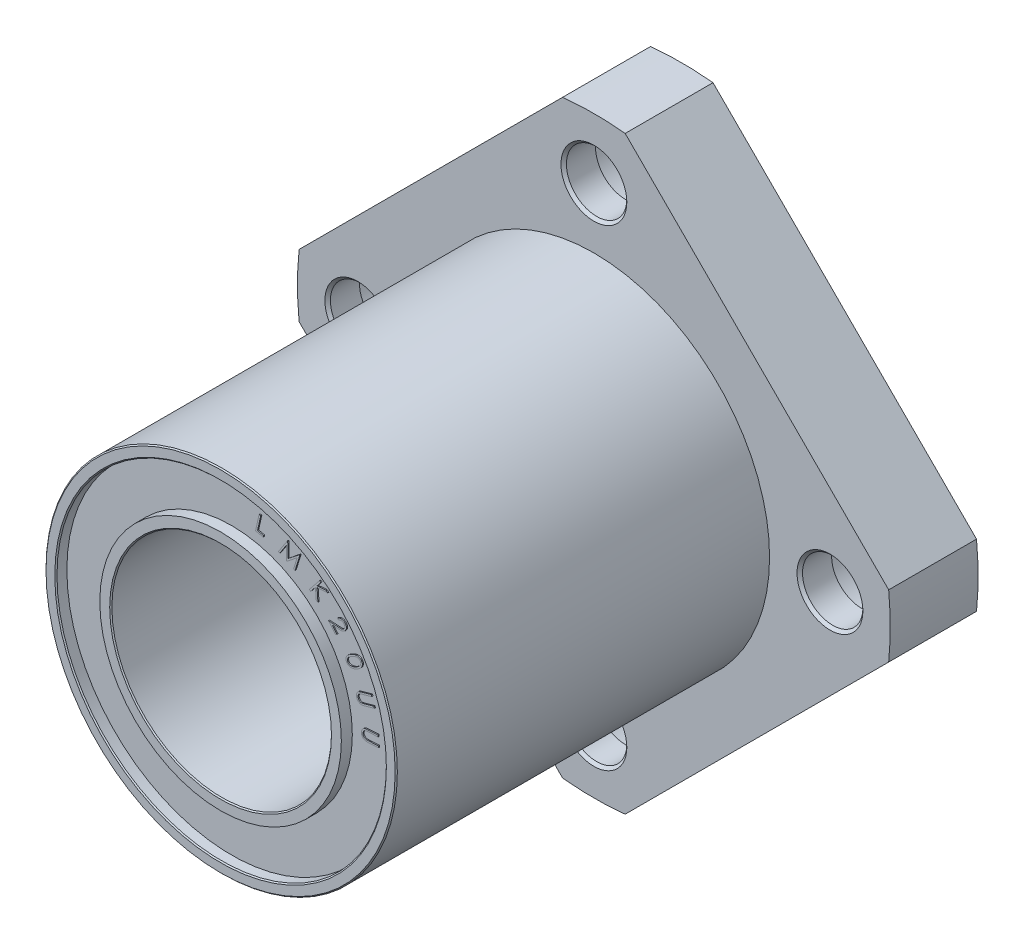
from build123d import *

# Parameters (mm, degrees)
BOSS_EXTRUDE1_DEPTH          = 8
SKETCH2_R                    = 16
BOSS_EXTRUDE2_DEPTH          = 34
SKETCH3_R                    = 4.5
CUT_EXTRUDE1_DEPTH           = 5.1
SKETCH4_R                    = 2.75
CUT_EXTRUDE2_DEPTH           = 2.9
CHAMFER1_SIZE                = 0.25
CIRPATTERN1_COUNT            = 4
CHAMFER1_OF_CIRPATTERN1_SIZE = 0.25
SKETCH5_R                    = 10
CUT_EXTRUDE3_DEPTH           = 43
SKETCH6_R                    = 15
SKETCH6_R_2                  = 11
CUT_EXTRUDE4_DEPTH           = 1
SKETCH7_R                    = 15
SKETCH7_R_2                  = 11
CUT_EXTRUDE5_DEPTH           = 1
BOSS_EXTRUDE3_DEPTH          = 0.1
CHAMFER2_SIZE                = 0.1
BOSS_EXTRUDE4_DEPTH          = 0.1


with BuildPart() as part:
    # Sketch1 → Boss-Extrude1 (new body)
    with BuildSketch(Plane.XY):
        with BuildLine():
            Line((-2.849242405, 26.849242405), (-26.849242405, 2.849242405))
            ThreePointArc((-26.849242405, 2.849242405), (-27, 0), (-26.849242405, -2.849242405))
            Line((-26.849242405, -2.849242405), (-2.849242405, -26.849242405))
            ThreePointArc((-2.849242405, -26.849242405), (0, -27), (2.849242405, -26.849242405))
            Line((2.849242405, -26.849242405), (26.849242405, -2.849242405))
            ThreePointArc((26.849242405, -2.849242405), (27, 0), (26.849242405, 2.849242405))
            Line((26.849242405, 2.849242405), (2.849242405, 26.849242405))
            ThreePointArc((2.849242405, 26.849242405), (0, 27), (-2.849242405, 26.849242405))
        make_face()
    extrude(amount=BOSS_EXTRUDE1_DEPTH)

    # Sketch2 → Boss-Extrude2 (add)
    with BuildSketch(Plane.XY.offset(8)):
        Circle(SKETCH2_R)
    extrude(amount=BOSS_EXTRUDE2_DEPTH)

    # Sketch3 → Cut-Extrude1 (cut)
    with BuildSketch(Plane(origin=(0, 0, 0), x_dir=(-1, 0, 0), z_dir=(0, 0, -1))):
        with Locations((0, 21.5)):
            Circle(SKETCH3_R)
    cut_extrude1 = extrude(amount=-CUT_EXTRUDE1_DEPTH, mode=Mode.SUBTRACT)

    # Sketch4 → Cut-Extrude2 (cut)
    with BuildSketch(Plane(origin=(0, 0, 5.1), x_dir=(-1, 0, 0), z_dir=(0, 0, -1))):
        with Locations((0, 21.5)):
            Circle(SKETCH4_R)
    cut_extrude2 = extrude(amount=-CUT_EXTRUDE2_DEPTH, mode=Mode.SUBTRACT)

    # Chamfer1
    chamfer1_edges = [part.edges().sort_by_distance(p)[0] for p in [
        (4.5, 21.5, 0),
        (2.75, 21.5, 8),
    ]]
    chamfer(chamfer1_edges, length=CHAMFER1_SIZE)

    # CirPattern1: Cut-Extrude1, Cut-Extrude2 ×4 about axis
    cirpattern1_axis = Axis((0, 0, 0), (0, 0, 1))
    for i in range(1, CIRPATTERN1_COUNT):
        add(cut_extrude1.rotate(cirpattern1_axis, i * 360 / CIRPATTERN1_COUNT), mode=Mode.SUBTRACT)
        add(cut_extrude2.rotate(cirpattern1_axis, i * 360 / CIRPATTERN1_COUNT), mode=Mode.SUBTRACT)

    # Chamfer1 of CirPattern1
    chamfer1_of_cirpattern1_edges = [part.edges().sort_by_distance(p)[0] for p in [
        (-21.5, 4.5, 0),
        (-21.5, 2.75, 8),
        (-4.5, -21.5, 0),
        (-2.75, -21.5, 8),
        (21.5, -4.5, 0),
        (21.5, -2.75, 8),
    ]]
    chamfer(chamfer1_of_cirpattern1_edges, length=CHAMFER1_OF_CIRPATTERN1_SIZE)

    # Sketch5 → Cut-Extrude3 (cut, through all)
    with BuildSketch(Plane.XY.offset(42)):
        Circle(SKETCH5_R)
    extrude(amount=-CUT_EXTRUDE3_DEPTH, mode=Mode.SUBTRACT)

    # Sketch6 → Cut-Extrude4 (cut)
    with BuildSketch(Plane.XY.offset(42)):
        Circle(SKETCH6_R)
        Circle(SKETCH6_R_2, mode=Mode.SUBTRACT)
    extrude(amount=-CUT_EXTRUDE4_DEPTH, mode=Mode.SUBTRACT)

    # Sketch7 → Cut-Extrude5 (cut)
    with BuildSketch(Plane(origin=(0, 0, 0), x_dir=(-1, 0, 0), z_dir=(0, 0, -1))):
        Circle(SKETCH7_R)
        Circle(SKETCH7_R_2, mode=Mode.SUBTRACT)
    extrude(amount=-CUT_EXTRUDE5_DEPTH, mode=Mode.SUBTRACT)

    # Sketch8 → Boss-Extrude3 (add)
    with BuildSketch(Plane.XY.offset(41)):
        with BuildLine():
            Line((13.427089752, 1.23927114), (13.435202732, 1.090232679))
            Line((13.435202732, 1.090232679), (12.534661867, 1.039751909))
            add(Edge.make_bspline(
                [(12.534661867, 1.039751909), (12.521938092, 1.039105283), (12.497682448, 1.037872603), (12.463252241, 1.035275518), (12.432586914, 1.033302619), (12.405842357, 1.031197911), (12.38290086, 1.029112812), (12.363764001, 1.02704565), (12.348313102, 1.025044585), (12.339344068, 1.023358043), (12.335443117, 1.022624506)],
                knots=[0, 0, 0, 0, 3.8219e-05, 7.2858e-05, 0.000103579, 0.000130404, 0.000153337, 0.000172683, 0.000188151, 0.000200057, 0.000200057, 0.000200057, 0.000200057], degree=3))
            add(Edge.make_bspline(
                [(12.335443117, 1.022624506), (12.321327399, 1.019661816), (12.294081466, 1.013943279), (12.255805741, 0.999996763), (12.221149074, 0.983428508), (12.189942518, 0.962987015), (12.162506723, 0.937659089), (12.137484031, 0.90766722), (12.116197683, 0.871686149), (12.097208807, 0.831951848), (12.082455491, 0.789484408), (12.072116386, 0.746434196), (12.066635935, 0.703351793), (12.067356, 0.674780167), (12.067714752, 0.660545179)],
                knots=[0, 0, 0, 0, 4.322e-05, 8.3423e-05, 0.000121857, 0.000158276, 0.000194861, 0.000233488, 0.000275024, 0.000319916, 0.000365436, 0.000409602, 0.000452575, 0.000495244, 0.000495244, 0.000495244, 0.000495244], degree=3))
            add(Edge.make_bspline(
                [(12.067714752, 0.660545179), (12.068696913, 0.648278297), (12.070648098, 0.623908614), (12.079246417, 0.588237365), (12.090870833, 0.553427222), (12.106487478, 0.520023427), (12.125257958, 0.488484833), (12.147416847, 0.459702961), (12.172426236, 0.4338272), (12.200184275, 0.410693877), (12.231077449, 0.391313874), (12.26437645, 0.374537533), (12.300584605, 0.361243554), (12.326053685, 0.355289747), (12.339048886, 0.352251909)],
                knots=[0, 0, 0, 0, 3.6866e-05, 7.3239e-05, 0.000109728, 0.000146832, 0.000183626, 0.000219626, 0.000255539, 0.000291396, 0.000327739, 0.000364693, 0.000403099, 0.000443109, 0.000443109, 0.000443109, 0.000443109], degree=3))
            add(Edge.make_bspline(
                [(12.339048886, 0.352251909), (12.344445352, 0.35125697), (12.356472762, 0.349039491), (12.376602623, 0.347680621), (12.400317816, 0.345951944), (12.427792454, 0.34547477), (12.458940627, 0.345987565), (12.493809349, 0.34637775), (12.532367597, 0.348057356), (12.559302463, 0.349429274), (12.573423886, 0.350148544)],
                knots=[0, 0, 0, 0, 1.645e-05, 3.6663e-05, 6.0448e-05, 8.7798e-05, 0.00011905, 0.000153911, 0.000192402, 0.000234822, 0.000234822, 0.000234822, 0.000234822], degree=3))
            Line((12.573423886, 0.350148544), (13.473964752, 0.400629313))
            Line((13.473964752, 0.400629313), (13.482378213, 0.251590852))
            Line((13.482378213, 0.251590852), (12.581837348, 0.201110082))
            add(Edge.make_bspline(
                [(12.581837348, 0.201110082), (12.56561504, 0.200299528), (12.533884566, 0.198714101), (12.487384842, 0.198232005), (12.443199362, 0.198783334), (12.401298345, 0.200489862), (12.361692312, 0.203734651), (12.324410009, 0.208563237), (12.289523247, 0.214566137), (12.256604326, 0.221633293), (12.225359503, 0.231069465), (12.195123236, 0.242731892), (12.166051243, 0.257342613), (12.137532203, 0.273927513), (12.10986458, 0.293061464), (12.083546361, 0.31532073), (12.057466873, 0.339293333), (12.032750759, 0.365901306), (12.009598728, 0.394545285), (11.989149564, 0.425202797), (11.971616871, 0.457618882), (11.956854527, 0.491706309), (11.944867901, 0.527512315), (11.935569746, 0.564986558), (11.928758933, 0.604143572), (11.926855925, 0.630971712), (11.925887829, 0.644619698)],
                knots=[0, 0, 0, 0, 4.8723e-05, 9.5302e-05, 0.000139476, 0.000181282, 0.000221083, 0.000258652, 0.000294022, 0.000327265, 0.000359586, 0.000391839, 0.000424359, 0.000457083, 0.000490759, 0.000525115, 0.000560408, 0.000596976, 0.000633954, 0.00067079, 0.000707361, 0.00074437, 0.000782093, 0.0008205, 0.000860118, 0.000901142, 0.000901142, 0.000901142, 0.000901142], degree=3))
            add(Edge.make_bspline(
                [(11.925887829, 0.644619698), (11.92526274, 0.659442192), (11.924037588, 0.688493761), (11.92605034, 0.731463494), (11.930449834, 0.772930422), (11.937674288, 0.813001355), (11.947567537, 0.851717442), (11.960457025, 0.888897117), (11.976261989, 0.924602831), (11.99442907, 0.958727457), (12.015113065, 0.990726777), (12.037723114, 1.02046248), (12.062470061, 1.047384184), (12.088606594, 1.072323824), (12.116996039, 1.094376799), (12.147475956, 1.113405297), (12.179413753, 1.1306766), (12.202025381, 1.13954085), (12.213447925, 1.144018736)],
                knots=[0, 0, 0, 0, 4.4487e-05, 8.7194e-05, 0.000128904, 0.000169514, 0.000209233, 0.000248669, 0.000287416, 0.000326267, 0.000364523, 0.000401604, 0.000438189, 0.000474113, 0.000509875, 0.000545803, 0.000581826, 0.0006186, 0.0006186, 0.0006186, 0.0006186], degree=3))
            add(Edge.make_bspline(
                [(12.213447925, 1.144018736), (12.221321464, 1.146755288), (12.238264541, 1.152644078), (12.266615842, 1.159209917), (12.299159447, 1.16582175), (12.336136628, 1.171840261), (12.377473834, 1.176691337), (12.423116468, 1.181707219), (12.473345979, 1.185357946), (12.508318501, 1.187614224), (12.526548886, 1.188790371)],
                knots=[0, 0, 0, 0, 2.4991e-05, 5.3777e-05, 8.719e-05, 0.000124635, 0.000166116, 0.000212042, 0.000262374, 0.00031718, 0.00031718, 0.00031718, 0.00031718], degree=3))
            Line((12.526548886, 1.188790371), (13.427089752, 1.23927114))
        make_face()
        with BuildLine():
            Line((12.834294046, 4.128094889), (12.874558469, 3.984465081))
            Line((12.874558469, 3.984465081), (12.007370969, 3.740775178))
            add(Edge.make_bspline(
                [(12.007370969, 3.740775178), (11.995148675, 3.737279133), (11.971894452, 3.730627534), (11.93884085, 3.721012984), (11.909481631, 3.712339927), (11.883700624, 3.704547159), (11.861821774, 3.697354), (11.843427123, 3.691336213), (11.828864323, 3.686094514), (11.820460038, 3.682511632), (11.816866161, 3.680979504)],
                knots=[0, 0, 0, 0, 3.8137e-05, 7.256e-05, 0.00010327, 0.000129979, 0.000153355, 0.000172359, 0.000188044, 0.000199763, 0.000199763, 0.000199763, 0.000199763], degree=3))
            add(Edge.make_bspline(
                [(11.816866161, 3.680979504), (11.803786347, 3.675073174), (11.77843311, 3.663624646), (11.744051277, 3.641922979), (11.713611167, 3.618369949), (11.687896111, 3.591432709), (11.66631477, 3.560932882), (11.648912716, 3.526063187), (11.635562273, 3.486592235), (11.625820652, 3.443703883), (11.620537366, 3.3990839), (11.619755566, 3.354753166), (11.624228503, 3.311571603), (11.630863311, 3.283785918), (11.634173853, 3.269921812)],
                knots=[0, 0, 0, 0, 4.3007e-05, 8.3362e-05, 0.000121655, 0.00015821, 0.000194643, 0.000233344, 0.000274681, 0.000319364, 0.000365058, 0.000409233, 0.000452139, 0.000494867, 0.000494867, 0.000494867, 0.000494867], degree=3))
            add(Edge.make_bspline(
                [(11.634173853, 3.269921812), (11.637821783, 3.258306654), (11.645112071, 3.235094073), (11.660642257, 3.202115426), (11.679438717, 3.170704792), (11.701866493, 3.141517895), (11.72722005, 3.114876869), (11.755110877, 3.091593222), (11.784949964, 3.071589328), (11.817114568, 3.055229831), (11.851400312, 3.042590517), (11.887729631, 3.033993162), (11.925882763, 3.028704828), (11.951964508, 3.028261518), (11.965303661, 3.028034793)],
                knots=[0, 0, 0, 0, 3.6488e-05, 7.2921e-05, 0.000109045, 0.000146126, 0.000183106, 0.000219155, 0.000254907, 0.000290653, 0.000327158, 0.000364254, 0.000402458, 0.00044245, 0.00044245, 0.00044245, 0.00044245], degree=3))
            add(Edge.make_bspline(
                [(11.965303661, 3.028034793), (11.970818508, 3.028259408), (11.982989716, 3.028755131), (12.002932587, 3.031403005), (12.026374242, 3.035342348), (12.053331039, 3.040759008), (12.083627511, 3.047817533), (12.117469716, 3.055795994), (12.154624282, 3.065933256), (12.180647962, 3.07300893), (12.194270007, 3.076712678)],
                knots=[0, 0, 0, 0, 1.6551e-05, 3.6528e-05, 6.0289e-05, 8.7868e-05, 0.000118993, 0.000153611, 0.000192167, 0.000234518, 0.000234518, 0.000234518, 0.000234518], degree=3))
            Line((12.194270007, 3.076712678), (13.061457507, 3.320402581))
            Line((13.061457507, 3.320402581), (13.10172193, 3.176772774))
            Line((13.10172193, 3.176772774), (12.23453443, 2.93308287))
            add(Edge.make_bspline(
                [(12.23453443, 2.93308287), (12.218832169, 2.928787142), (12.188225823, 2.920414047), (12.143121106, 2.90966115), (12.100091957, 2.900418417), (12.058835945, 2.893666564), (12.019583265, 2.888161238), (11.982301451, 2.884367706), (11.946989434, 2.883060996), (11.913381772, 2.882737102), (11.880803855, 2.885131743), (11.848888101, 2.890364189), (11.81719988, 2.897816481), (11.785848698, 2.908095411), (11.754898615, 2.921143119), (11.724105665, 2.936464974), (11.693710364, 2.954598379), (11.66387792, 2.975235683), (11.63500541, 2.997957007), (11.608916481, 3.023959675), (11.584388485, 3.051343459), (11.56274529, 3.081511297), (11.54297699, 3.11357717), (11.526499372, 3.148477821), (11.511056366, 3.18496689), (11.503424522, 3.210641713), (11.499558469, 3.223647774)],
                knots=[0, 0, 0, 0, 4.8834e-05, 9.5186e-05, 0.000139091, 0.000180832, 0.000220565, 0.000257999, 0.000293187, 0.000326541, 0.000358782, 0.00039104, 0.000423472, 0.00045635, 0.000489888, 0.000524155, 0.000559455, 0.000595961, 0.00063294, 0.000669488, 0.00070632, 0.000743103, 0.000780721, 0.000819156, 0.000858774, 0.000899447, 0.000899447, 0.000899447, 0.000899447], degree=3))
            add(Edge.make_bspline(
                [(11.499558469, 3.223647774), (11.49571903, 3.237918695), (11.488151139, 3.266048005), (11.480991418, 3.308517717), (11.475811364, 3.350017065), (11.474561282, 3.390710867), (11.475472581, 3.430502197), (11.480152495, 3.469475107), (11.487601849, 3.507667833), (11.498122735, 3.544829455), (11.511287374, 3.580494236), (11.526909233, 3.61429321), (11.545090085, 3.646000735), (11.56539948, 3.675800628), (11.58841597, 3.703308504), (11.613884387, 3.728582558), (11.641360965, 3.752270419), (11.66156936, 3.765813917), (11.671733949, 3.772626139)],
                knots=[0, 0, 0, 0, 4.4309e-05, 8.7338e-05, 0.000129082, 0.000169675, 0.000209357, 0.00024838, 0.000287273, 0.000325989, 0.000364112, 0.000401216, 0.000437554, 0.000473643, 0.000509269, 0.000544964, 0.000581207, 0.000617885, 0.000617885, 0.000617885, 0.000617885], degree=3))
            add(Edge.make_bspline(
                [(11.671733949, 3.772626139), (11.678795257, 3.776921276), (11.694125667, 3.786246207), (11.72006606, 3.799306383), (11.75040416, 3.812695119), (11.785156887, 3.826598108), (11.824410878, 3.840524247), (11.867995711, 3.854934195), (11.916005786, 3.869681719), (11.949562826, 3.879350249), (11.967106546, 3.884404985)],
                knots=[0, 0, 0, 0, 2.4787e-05, 5.3815e-05, 8.7039e-05, 0.000124256, 0.000166076, 0.000211971, 0.000261965, 0.000316736, 0.000316736, 0.000316736, 0.000316736], degree=3))
            Line((11.967106546, 3.884404985), (12.834294046, 4.128094889))
        make_face()
        with BuildLine():
            add(Edge.make_bspline(
                [(11.027657403, 6.390487463), (11.049019815, 6.401549045), (11.090436991, 6.422995102), (11.151920651, 6.451854378), (11.210515223, 6.477182902), (11.266282658, 6.498919018), (11.319335723, 6.516749785), (11.369562348, 6.53094796), (11.417063796, 6.541735716), (11.462200682, 6.548275744), (11.505148692, 6.551941832), (11.546405499, 6.552938244), (11.586239167, 6.551029405), (11.624638332, 6.547056318), (11.66163435, 6.539899668), (11.69729367, 6.53084512), (11.731536462, 6.518660489), (11.764123922, 6.503956686), (11.795185285, 6.487119279), (11.824425036, 6.468133844), (11.851762437, 6.447137086), (11.87708028, 6.424129641), (11.900790599, 6.399393497), (11.922274965, 6.372358807), (11.941958033, 6.343415315), (11.953386918, 6.322969107), (11.959147788, 6.312662944)],
                knots=[0, 0, 0, 0, 7.2164e-05, 0.00013991, 0.000203709, 0.000263639, 0.000319416, 0.000371546, 0.000420173, 0.00046543, 0.00050825, 0.000549426, 0.000589131, 0.000627821, 0.000665126, 0.000702076, 0.000738095, 0.000774005, 0.000809233, 0.000843988, 0.000878485, 0.000912523, 0.00094653, 0.000981162, 0.001015998, 0.001051405, 0.001051405, 0.001051405, 0.001051405], degree=3))
            add(Edge.make_bspline(
                [(11.959147788, 6.312662944), (11.964533418, 6.301926237), (11.975225571, 6.280610535), (11.988014556, 6.247478369), (11.99831124, 6.214053185), (12.005929292, 6.180102602), (12.010642853, 6.145629609), (12.012907379, 6.110663629), (12.01172646, 6.075317316), (12.008658321, 6.039624069), (12.002215618, 6.003762363), (11.992952194, 5.967835613), (11.980217457, 5.932263981), (11.964757595, 5.896674226), (11.946124503, 5.861354836), (11.924328678, 5.826101113), (11.899679957, 5.79096312), (11.871945492, 5.755908443), (11.8404408, 5.721171085), (11.804946781, 5.686617732), (11.765179134, 5.652476416), (11.721368387, 5.618372418), (11.673322245, 5.584507299), (11.620986888, 5.551007924), (11.564684275, 5.517409172), (11.525144866, 5.496293328), (11.504820865, 5.485439386)],
                knots=[0, 0, 0, 0, 3.6018e-05, 7.1506e-05, 0.000106389, 0.000140871, 0.000175759, 0.000210678, 0.000245846, 0.000281756, 0.000318066, 0.000355016, 0.000392935, 0.000431286, 0.000471339, 0.000512619, 0.00055555, 0.000600037, 0.000646627, 0.000696137, 0.000748545, 0.000803783, 0.000862641, 0.00092482, 0.000990163, 0.001059276, 0.001059276, 0.001059276, 0.001059276], degree=3))
            add(Edge.make_bspline(
                [(11.504820865, 5.485439386), (11.484478447, 5.474838825), (11.444857732, 5.454192222), (11.385504049, 5.427100269), (11.328740793, 5.402750414), (11.273927596, 5.382409128), (11.221437047, 5.36495116), (11.170873271, 5.351906365), (11.122693688, 5.341675525), (11.076478269, 5.335428525), (11.032224478, 5.332092146), (10.989572937, 5.331431929), (10.948410941, 5.333484597), (10.908758531, 5.338284444), (10.870640261, 5.345605065), (10.833911081, 5.354910419), (10.798920147, 5.367890943), (10.765329849, 5.382643831), (10.733681183, 5.400244266), (10.70393797, 5.419837921), (10.675821615, 5.441098424), (10.650003525, 5.464640036), (10.626055045, 5.490030231), (10.604227939, 5.517475014), (10.58379061, 5.546589162), (10.572245025, 5.567457726), (10.566419422, 5.577987463)],
                knots=[0, 0, 0, 0, 6.8804e-05, 0.000134009, 0.000195678, 0.000254058, 0.000309361, 0.000361545, 0.000410633, 0.000457038, 0.000501332, 0.000543704, 0.000584924, 0.000624878, 0.000663419, 0.000701318, 0.000738388, 0.000775243, 0.000811287, 0.000846873, 0.000882031, 0.000916917, 0.000951567, 0.000986621, 0.001022045, 0.001058123, 0.001058123, 0.001058123, 0.001058123], degree=3))
            add(Edge.make_bspline(
                [(10.566419422, 5.577987463), (10.56116293, 5.58853573), (10.55071185, 5.609508036), (10.537787073, 5.641904601), (10.52779283, 5.674893699), (10.520725253, 5.708290711), (10.51564689, 5.741995516), (10.514118563, 5.77618613), (10.514475397, 5.810751986), (10.518296319, 5.845694899), (10.524457647, 5.880801885), (10.53386549, 5.915767193), (10.546236042, 5.950425969), (10.56169767, 5.984838901), (10.580100217, 6.018990799), (10.601108339, 6.05319948), (10.625655929, 6.086661596), (10.652800871, 6.120455298), (10.684060155, 6.153950756), (10.719558242, 6.187590022), (10.759769055, 6.221299094), (10.804497672, 6.255039673), (10.853620067, 6.289176226), (10.907561867, 6.322907296), (10.965761227, 6.357293448), (11.006641226, 6.379216795), (11.027657403, 6.390487463)],
                knots=[0, 0, 0, 0, 3.5346e-05, 7.0275e-05, 0.000104496, 0.00013862, 0.000172615, 0.000206618, 0.000241178, 0.00027622, 0.000311938, 0.000348017, 0.000384703, 0.000422229, 0.000461079, 0.000501021, 0.000542554, 0.000585493, 0.000630994, 0.000679879, 0.000732125, 0.000788316, 0.000847913, 0.00091152, 0.000979133, 0.001050668, 0.001050668, 0.001050668, 0.001050668], degree=3))
        make_face()
        with BuildLine():
            add(Edge.make_bspline(
                [(11.091058845, 6.263684578), (11.072989793, 6.253942202), (11.0380584, 6.235108077), (10.987950638, 6.206543255), (10.942041243, 6.178397805), (10.90019934, 6.150670143), (10.862169481, 6.123821687), (10.828637678, 6.097041277), (10.798828088, 6.07120313), (10.773154279, 6.045481762), (10.750624084, 6.01994828), (10.730671648, 5.994245707), (10.712951286, 5.968338619), (10.697882581, 5.941920133), (10.684828286, 5.915506021), (10.674283193, 5.888669625), (10.666091707, 5.861539716), (10.658716433, 5.82562749), (10.654309202, 5.78158653), (10.657283474, 5.730286624), (10.668069744, 5.68149279), (10.681854809, 5.651705607), (10.688715095, 5.636881694)],
                knots=[0, 0, 0, 0, 6.1583e-05, 0.000119054, 0.000173011, 0.000223097, 0.000269624, 0.00031261, 0.000351788, 0.000387908, 0.000421546, 0.000453882, 0.000485468, 0.00051562, 0.00054505, 0.000573786, 0.00060202, 0.000629954, 0.000683683, 0.000734253, 0.000783599, 0.000832485, 0.000832485, 0.000832485, 0.000832485], degree=3))
            add(Edge.make_bspline(
                [(10.688715095, 5.636881694), (10.697048729, 5.622719797), (10.713708681, 5.594408433), (10.747602052, 5.557768223), (10.787757612, 5.526547665), (10.825964038, 5.505581106), (10.859009085, 5.491525996), (10.88568606, 5.483597508), (10.913357967, 5.477200983), (10.942293077, 5.472915079), (10.972545271, 5.471376209), (11.003963432, 5.471167509), (11.03656428, 5.473774612), (11.058519822, 5.476723102), (11.069724711, 5.478227848)],
                knots=[0, 0, 0, 0, 4.918e-05, 9.8316e-05, 0.000148626, 0.000201218, 0.000228562, 0.000256221, 0.000284576, 0.000313727, 0.000343829, 0.00037538, 0.000407921, 0.000441836, 0.000441836, 0.000441836, 0.000441836], degree=3))
            add(Edge.make_bspline(
                [(11.069724711, 5.478227848), (11.083872513, 5.480597407), (11.112712356, 5.485427677), (11.156177894, 5.495341564), (11.200516798, 5.50816731), (11.245904384, 5.523249127), (11.292430883, 5.540507799), (11.339677265, 5.560944065), (11.388059875, 5.583323344), (11.420243891, 5.599903728), (11.43661173, 5.608336021)],
                knots=[0, 0, 0, 0, 4.3029e-05, 8.7712e-05, 0.000133651, 0.000181446, 0.000231174, 0.000282466, 0.000335835, 0.000391065, 0.000391065, 0.000391065, 0.000391065], degree=3))
            add(Edge.make_bspline(
                [(11.43661173, 5.608336021), (11.452912329, 5.617017357), (11.484710566, 5.633952391), (11.530077276, 5.661000917), (11.572825996, 5.687448695), (11.612315862, 5.714680393), (11.648886514, 5.7419544), (11.68273332, 5.769133428), (11.713033865, 5.79702636), (11.740946337, 5.824492984), (11.765383964, 5.852666188), (11.787887144, 5.880106888), (11.807126067, 5.907919416), (11.823809862, 5.935569745), (11.837522298, 5.963302623), (11.849246441, 5.990642229), (11.857666357, 6.018170202), (11.865011387, 6.054107823), (11.869485775, 6.097949616), (11.866411677, 6.14881147), (11.856022914, 6.197275301), (11.842236834, 6.226732862), (11.835349711, 6.241449002)],
                knots=[0, 0, 0, 0, 5.5396e-05, 0.000108063, 0.00015842, 0.000206177, 0.000251911, 0.000295273, 0.000336324, 0.000375419, 0.000412675, 0.000448152, 0.000481828, 0.000514035, 0.000544942, 0.000574574, 0.000603183, 0.000631117, 0.000684546, 0.000734817, 0.000783509, 0.000832119, 0.000832119, 0.000832119, 0.000832119], degree=3))
            add(Edge.make_bspline(
                [(11.835349711, 6.241449002), (11.826892619, 6.255591228), (11.810013635, 6.283816818), (11.77614967, 6.320800088), (11.735249491, 6.351665946), (11.696792065, 6.373184609), (11.663126184, 6.386926129), (11.636488831, 6.395799653), (11.608558778, 6.401900819), (11.579592975, 6.406681258), (11.549321958, 6.408427317), (11.518006118, 6.40900799), (11.48562085, 6.406537206), (11.45175121, 6.402861831), (11.415920889, 6.396040145), (11.377647983, 6.386247579), (11.336556304, 6.373731424), (11.29288511, 6.357493413), (11.246297244, 6.338535839), (11.19686991, 6.316646604), (11.144657883, 6.291602504), (11.10933533, 6.273204181), (11.091058845, 6.263684578)],
                knots=[0, 0, 0, 0, 4.9342e-05, 9.8479e-05, 0.000149263, 0.000202527, 0.000230148, 0.000258275, 0.00028663, 0.000315826, 0.000346247, 0.000377499, 0.000409719, 0.000443599, 0.000479667, 0.00051902, 0.000562077, 0.000608466, 0.000658741, 0.000712956, 0.000770612, 0.00083243, 0.00083243, 0.00083243, 0.00083243], degree=3))
        make_face(mode=Mode.SUBTRACT)
        with BuildLine():
            Line((9.840154707, 8.509788227), (9.750010476, 8.619764188))
            add(Edge.make_bspline(
                [(9.750010476, 8.619764188), (9.764459331, 8.630437009), (9.792787316, 8.651361817), (9.837570375, 8.677887053), (9.883091207, 8.699700281), (9.929490469, 8.716619181), (9.976620667, 8.728604156), (10.024373266, 8.736383491), (10.073036191, 8.738643903), (10.122011173, 8.736164383), (10.170357338, 8.729485357), (10.216987735, 8.717841459), (10.261615823, 8.702394694), (10.304048448, 8.681969107), (10.344361435, 8.657231767), (10.38273203, 8.628300871), (10.418784096, 8.594661928), (10.44054108, 8.569494108), (10.451633072, 8.556663227)],
                knots=[0, 0, 0, 0, 5.3862e-05, 0.000105601, 0.000155868, 0.000205106, 0.000253497, 0.000301564, 0.000350001, 0.000399339, 0.000448505, 0.000496167, 0.000543303, 0.000589939, 0.000637144, 0.000684981, 0.000733879, 0.000784735, 0.000784735, 0.000784735, 0.000784735], degree=3))
            add(Edge.make_bspline(
                [(10.451633072, 8.556663227), (10.461869139, 8.543503217), (10.481918695, 8.517726486), (10.507703884, 8.477049871), (10.52810113, 8.435318365), (10.544301967, 8.393142431), (10.555390377, 8.350086651), (10.562260987, 8.306307762), (10.563513835, 8.261646245), (10.560526035, 8.216776511), (10.553323014, 8.172750338), (10.542571291, 8.130228344), (10.527656043, 8.090010512), (10.50982676, 8.051520042), (10.487469163, 8.015618039), (10.462038423, 7.981451269), (10.432311439, 7.949833859), (10.410427544, 7.930588405), (10.399349418, 7.920845919)],
                knots=[0, 0, 0, 0, 5e-05, 9.7936e-05, 0.000144163, 0.000189144, 0.000233237, 0.000277305, 0.000321802, 0.000366974, 0.000412026, 0.000455462, 0.000498334, 0.000540539, 0.000582488, 0.000624976, 0.000668134, 0.000712379, 0.000712379, 0.000712379, 0.000712379], degree=3))
            add(Edge.make_bspline(
                [(10.399349418, 7.920845919), (10.382930191, 7.908268257), (10.350263467, 7.883244486), (10.295978378, 7.853975646), (10.238625101, 7.831372306), (10.187749912, 7.818825705), (10.143829407, 7.812308972), (10.106667141, 7.807997607), (10.065345037, 7.805480565), (10.019953074, 7.804086467), (9.970363904, 7.803455978), (9.916558578, 7.804024847), (9.858668288, 7.806313089), (9.81871836, 7.808327349), (9.798087399, 7.809367554)],
                knots=[0, 0, 0, 0, 6.1968e-05, 0.000123287, 0.000184276, 0.000246513, 0.000279958, 0.000317455, 0.000358709, 0.000404107, 0.00045369, 0.000507479, 0.00056551, 0.000627482, 0.000627482, 0.000627482, 0.000627482], degree=3))
            Line((9.798087399, 7.809367554), (9.25571961, 7.841819477))
            Line((9.25571961, 7.841819477), (9.690214803, 7.312672842))
            Line((9.690214803, 7.312672842), (9.57963788, 7.22192765))
            Line((9.57963788, 7.22192765), (8.940214803, 8.000473323))
            Line((8.940214803, 8.000473323), (9.772847014, 7.950893996))
            add(Edge.make_bspline(
                [(9.772847014, 7.950893996), (9.793075266, 7.949613212), (9.831913943, 7.947154079), (9.887919329, 7.944868343), (9.939202036, 7.943186317), (9.985789187, 7.942946474), (10.027668808, 7.943463912), (10.064842423, 7.944935371), (10.097450489, 7.947147338), (10.134339979, 7.951857074), (10.176275772, 7.961020135), (10.222766004, 7.978483325), (10.266547045, 8.000789231), (10.292350934, 8.020587118), (10.305298937, 8.0305214)],
                knots=[0, 0, 0, 0, 6.0804e-05, 0.000116745, 0.000168149, 0.000214725, 0.000256496, 0.000293786, 0.000326327, 0.000354503, 0.000405314, 0.000454656, 0.000503176, 0.000552043, 0.000552043, 0.000552043, 0.000552043], degree=3))
            add(Edge.make_bspline(
                [(10.305298937, 8.0305214), (10.313042034, 8.037293875), (10.328259382, 8.05060368), (10.348615588, 8.072765359), (10.366167015, 8.0966325), (10.38083973, 8.122199378), (10.39289401, 8.149212612), (10.402738961, 8.177585392), (10.409184824, 8.207772299), (10.41297057, 8.239043167), (10.414404952, 8.270731606), (10.412072164, 8.302105059), (10.407440345, 8.33272719), (10.399575657, 8.362588135), (10.388207293, 8.391413079), (10.374511777, 8.419872063), (10.357256747, 8.447214854), (10.343905864, 8.464422145), (10.337149899, 8.473129573)],
                knots=[0, 0, 0, 0, 3.0844e-05, 6.0618e-05, 9.0066e-05, 0.000119547, 0.000148867, 0.000178704, 0.00020947, 0.000241262, 0.000273135, 0.000304456, 0.00033548, 0.000365946, 0.00039686, 0.000428306, 0.000460571, 0.000493624, 0.000493624, 0.000493624, 0.000493624], degree=3))
            add(Edge.make_bspline(
                [(10.337149899, 8.473129573), (10.329587919, 8.481883651), (10.314657106, 8.499168212), (10.290029727, 8.522252658), (10.263984864, 8.542318065), (10.236557363, 8.559175536), (10.20786728, 8.573050973), (10.17792907, 8.584095113), (10.146404804, 8.591395646), (10.113861261, 8.596303601), (10.080418327, 8.597862348), (10.046610183, 8.595597644), (10.012558077, 8.590278672), (9.978283278, 8.581044258), (9.943846691, 8.568373628), (9.909121473, 8.552407152), (9.874421249, 8.532637829), (9.851782992, 8.517542196), (9.840154707, 8.509788227)],
                knots=[0, 0, 0, 0, 3.4686e-05, 6.8485e-05, 0.00010106, 0.000133166, 0.000164882, 0.000196535, 0.000228676, 0.000261779, 0.000295166, 0.000328886, 0.000363268, 0.000398399, 0.000435186, 0.000473235, 0.000512928, 0.00055485, 0.00055485, 0.00055485, 0.00055485], degree=3))
        make_face()
        Polygon((8.121789312, 10.761124874), (8.240178735, 10.665571989), (7.888916716, 10.230175355), (8.703219601, 10.291773912), (8.860070562, 10.165271509), (7.882306139, 10.094959009), (7.967041716, 8.970259489), (7.813195562, 9.094358047), (7.740479216, 10.046581605), (7.303880658, 9.505415739), (7.185491235, 9.600968624), align=None)
        Polygon((4.360602801, 11.170652356), (5.192934532, 12.433272549), (5.215170109, 12.422755722), (5.240110012, 11.052262933), (6.310122032, 11.905027356), (6.332057128, 11.89481101), (5.886444147, 10.449198029), (5.753030686, 10.512298991), (6.078150878, 11.542948029), (5.141852801, 10.801361491), (5.107898474, 10.817286972), (5.084160493, 12.021914376), (4.491311936, 11.108753318), align=None)
        Polygon((2.607540121, 13.22433219), (2.753573775, 13.192180747), (2.465112236, 11.881784113), (3.022203583, 11.759187959), (2.991554544, 11.61916392), (2.288429544, 11.773911517), align=None)
    extrude(amount=BOSS_EXTRUDE3_DEPTH)

    # Chamfer2
    chamfer2_edges = [part.edges().sort_by_distance(p)[0] for p in [
        (-16, 0, 42),
        (-10, 0, 0),
        (-10, 0, 42),
        (-15, 0, 42),
    ]]
    chamfer(chamfer2_edges, length=CHAMFER2_SIZE)

    # Sketch9 → Boss-Extrude4 (add)
    with BuildSketch(Plane(origin=(0, 0, 1), x_dir=(-1, 0, 0), z_dir=(0, 0, -1))):
        with BuildLine():
            Line((13.427089752, 1.23927114), (13.435202732, 1.090232679))
            Line((13.435202732, 1.090232679), (12.534661867, 1.039751909))
            add(Edge.make_bspline(
                [(12.534661867, 1.039751909), (12.521938092, 1.039105283), (12.497682448, 1.037872603), (12.463252241, 1.035275518), (12.432586914, 1.033302619), (12.405842357, 1.031197911), (12.38290086, 1.029112812), (12.363764001, 1.02704565), (12.348313102, 1.025044585), (12.339344068, 1.023358043), (12.335443117, 1.022624506)],
                knots=[0, 0, 0, 0, 3.8219e-05, 7.2858e-05, 0.000103579, 0.000130404, 0.000153337, 0.000172683, 0.000188151, 0.000200057, 0.000200057, 0.000200057, 0.000200057], degree=3))
            add(Edge.make_bspline(
                [(12.335443117, 1.022624506), (12.321327399, 1.019661816), (12.294081466, 1.013943279), (12.255805741, 0.999996763), (12.221149074, 0.983428508), (12.189942518, 0.962987015), (12.162506723, 0.937659089), (12.137484031, 0.90766722), (12.116197683, 0.871686149), (12.097208807, 0.831951848), (12.082455491, 0.789484408), (12.072116386, 0.746434196), (12.066635935, 0.703351793), (12.067356, 0.674780167), (12.067714752, 0.660545179)],
                knots=[0, 0, 0, 0, 4.322e-05, 8.3423e-05, 0.000121857, 0.000158276, 0.000194861, 0.000233488, 0.000275024, 0.000319916, 0.000365436, 0.000409602, 0.000452575, 0.000495244, 0.000495244, 0.000495244, 0.000495244], degree=3))
            add(Edge.make_bspline(
                [(12.067714752, 0.660545179), (12.068696913, 0.648278297), (12.070648098, 0.623908614), (12.079246417, 0.588237365), (12.090870833, 0.553427222), (12.106487478, 0.520023427), (12.125257958, 0.488484833), (12.147416847, 0.459702961), (12.172426236, 0.4338272), (12.200184275, 0.410693877), (12.231077449, 0.391313874), (12.26437645, 0.374537533), (12.300584605, 0.361243554), (12.326053685, 0.355289747), (12.339048886, 0.352251909)],
                knots=[0, 0, 0, 0, 3.6866e-05, 7.3239e-05, 0.000109728, 0.000146832, 0.000183626, 0.000219626, 0.000255539, 0.000291396, 0.000327739, 0.000364693, 0.000403099, 0.000443109, 0.000443109, 0.000443109, 0.000443109], degree=3))
            add(Edge.make_bspline(
                [(12.339048886, 0.352251909), (12.344445352, 0.35125697), (12.356472762, 0.349039491), (12.376602623, 0.347680621), (12.400317816, 0.345951944), (12.427792454, 0.34547477), (12.458940627, 0.345987565), (12.493809349, 0.34637775), (12.532367597, 0.348057356), (12.559302463, 0.349429274), (12.573423886, 0.350148544)],
                knots=[0, 0, 0, 0, 1.645e-05, 3.6663e-05, 6.0448e-05, 8.7798e-05, 0.00011905, 0.000153911, 0.000192402, 0.000234822, 0.000234822, 0.000234822, 0.000234822], degree=3))
            Line((12.573423886, 0.350148544), (13.473964752, 0.400629313))
            Line((13.473964752, 0.400629313), (13.482378213, 0.251590852))
            Line((13.482378213, 0.251590852), (12.581837348, 0.201110082))
            add(Edge.make_bspline(
                [(12.581837348, 0.201110082), (12.56561504, 0.200299528), (12.533884566, 0.198714101), (12.487384842, 0.198232005), (12.443199362, 0.198783334), (12.401298345, 0.200489862), (12.361692312, 0.203734651), (12.324410009, 0.208563237), (12.289523247, 0.214566137), (12.256604326, 0.221633293), (12.225359503, 0.231069465), (12.195123236, 0.242731892), (12.166051243, 0.257342613), (12.137532203, 0.273927513), (12.10986458, 0.293061464), (12.083546361, 0.31532073), (12.057466873, 0.339293333), (12.032750759, 0.365901306), (12.009598728, 0.394545285), (11.989149564, 0.425202797), (11.971616871, 0.457618882), (11.956854527, 0.491706309), (11.944867901, 0.527512315), (11.935569746, 0.564986558), (11.928758933, 0.604143572), (11.926855925, 0.630971712), (11.925887829, 0.644619698)],
                knots=[0, 0, 0, 0, 4.8723e-05, 9.5302e-05, 0.000139476, 0.000181282, 0.000221083, 0.000258652, 0.000294022, 0.000327265, 0.000359586, 0.000391839, 0.000424359, 0.000457083, 0.000490759, 0.000525115, 0.000560408, 0.000596976, 0.000633954, 0.00067079, 0.000707361, 0.00074437, 0.000782093, 0.0008205, 0.000860118, 0.000901142, 0.000901142, 0.000901142, 0.000901142], degree=3))
            add(Edge.make_bspline(
                [(11.925887829, 0.644619698), (11.92526274, 0.659442192), (11.924037588, 0.688493761), (11.92605034, 0.731463494), (11.930449834, 0.772930422), (11.937674288, 0.813001355), (11.947567537, 0.851717442), (11.960457025, 0.888897117), (11.976261989, 0.924602831), (11.99442907, 0.958727457), (12.015113065, 0.990726777), (12.037723114, 1.02046248), (12.062470061, 1.047384184), (12.088606594, 1.072323824), (12.116996039, 1.094376799), (12.147475956, 1.113405297), (12.179413753, 1.1306766), (12.202025381, 1.13954085), (12.213447925, 1.144018736)],
                knots=[0, 0, 0, 0, 4.4487e-05, 8.7194e-05, 0.000128904, 0.000169514, 0.000209233, 0.000248669, 0.000287416, 0.000326267, 0.000364523, 0.000401604, 0.000438189, 0.000474113, 0.000509875, 0.000545803, 0.000581826, 0.0006186, 0.0006186, 0.0006186, 0.0006186], degree=3))
            add(Edge.make_bspline(
                [(12.213447925, 1.144018736), (12.221321464, 1.146755288), (12.238264541, 1.152644078), (12.266615842, 1.159209917), (12.299159447, 1.16582175), (12.336136628, 1.171840261), (12.377473834, 1.176691337), (12.423116468, 1.181707219), (12.473345979, 1.185357946), (12.508318501, 1.187614224), (12.526548886, 1.188790371)],
                knots=[0, 0, 0, 0, 2.4991e-05, 5.3777e-05, 8.719e-05, 0.000124635, 0.000166116, 0.000212042, 0.000262374, 0.00031718, 0.00031718, 0.00031718, 0.00031718], degree=3))
            Line((12.526548886, 1.188790371), (13.427089752, 1.23927114))
        make_face()
        with BuildLine():
            Line((12.834294046, 4.128094889), (12.874558469, 3.984465081))
            Line((12.874558469, 3.984465081), (12.007370969, 3.740775178))
            add(Edge.make_bspline(
                [(12.007370969, 3.740775178), (11.995148675, 3.737279133), (11.971894452, 3.730627534), (11.93884085, 3.721012984), (11.909481631, 3.712339927), (11.883700624, 3.704547159), (11.861821774, 3.697354), (11.843427123, 3.691336213), (11.828864323, 3.686094514), (11.820460038, 3.682511632), (11.816866161, 3.680979504)],
                knots=[0, 0, 0, 0, 3.8137e-05, 7.256e-05, 0.00010327, 0.000129979, 0.000153355, 0.000172359, 0.000188044, 0.000199763, 0.000199763, 0.000199763, 0.000199763], degree=3))
            add(Edge.make_bspline(
                [(11.816866161, 3.680979504), (11.803786347, 3.675073174), (11.77843311, 3.663624646), (11.744051277, 3.641922979), (11.713611167, 3.618369949), (11.687896111, 3.591432709), (11.66631477, 3.560932882), (11.648912716, 3.526063187), (11.635562273, 3.486592235), (11.625820652, 3.443703883), (11.620537366, 3.3990839), (11.619755566, 3.354753166), (11.624228503, 3.311571603), (11.630863311, 3.283785918), (11.634173853, 3.269921812)],
                knots=[0, 0, 0, 0, 4.3007e-05, 8.3362e-05, 0.000121655, 0.00015821, 0.000194643, 0.000233344, 0.000274681, 0.000319364, 0.000365058, 0.000409233, 0.000452139, 0.000494867, 0.000494867, 0.000494867, 0.000494867], degree=3))
            add(Edge.make_bspline(
                [(11.634173853, 3.269921812), (11.637821783, 3.258306654), (11.645112071, 3.235094073), (11.660642257, 3.202115426), (11.679438717, 3.170704792), (11.701866493, 3.141517895), (11.72722005, 3.114876869), (11.755110877, 3.091593222), (11.784949964, 3.071589328), (11.817114568, 3.055229831), (11.851400312, 3.042590517), (11.887729631, 3.033993162), (11.925882763, 3.028704828), (11.951964508, 3.028261518), (11.965303661, 3.028034793)],
                knots=[0, 0, 0, 0, 3.6488e-05, 7.2921e-05, 0.000109045, 0.000146126, 0.000183106, 0.000219155, 0.000254907, 0.000290653, 0.000327158, 0.000364254, 0.000402458, 0.00044245, 0.00044245, 0.00044245, 0.00044245], degree=3))
            add(Edge.make_bspline(
                [(11.965303661, 3.028034793), (11.970818508, 3.028259408), (11.982989716, 3.028755131), (12.002932587, 3.031403005), (12.026374242, 3.035342348), (12.053331039, 3.040759008), (12.083627511, 3.047817533), (12.117469716, 3.055795994), (12.154624282, 3.065933256), (12.180647962, 3.07300893), (12.194270007, 3.076712678)],
                knots=[0, 0, 0, 0, 1.6551e-05, 3.6528e-05, 6.0289e-05, 8.7868e-05, 0.000118993, 0.000153611, 0.000192167, 0.000234518, 0.000234518, 0.000234518, 0.000234518], degree=3))
            Line((12.194270007, 3.076712678), (13.061457507, 3.320402581))
            Line((13.061457507, 3.320402581), (13.10172193, 3.176772774))
            Line((13.10172193, 3.176772774), (12.23453443, 2.93308287))
            add(Edge.make_bspline(
                [(12.23453443, 2.93308287), (12.218832169, 2.928787142), (12.188225823, 2.920414047), (12.143121106, 2.90966115), (12.100091957, 2.900418417), (12.058835945, 2.893666564), (12.019583265, 2.888161238), (11.982301451, 2.884367706), (11.946989434, 2.883060996), (11.913381772, 2.882737102), (11.880803855, 2.885131743), (11.848888101, 2.890364189), (11.81719988, 2.897816481), (11.785848698, 2.908095411), (11.754898615, 2.921143119), (11.724105665, 2.936464974), (11.693710364, 2.954598379), (11.66387792, 2.975235683), (11.63500541, 2.997957007), (11.608916481, 3.023959675), (11.584388485, 3.051343459), (11.56274529, 3.081511297), (11.54297699, 3.11357717), (11.526499372, 3.148477821), (11.511056366, 3.18496689), (11.503424522, 3.210641713), (11.499558469, 3.223647774)],
                knots=[0, 0, 0, 0, 4.8834e-05, 9.5186e-05, 0.000139091, 0.000180832, 0.000220565, 0.000257999, 0.000293187, 0.000326541, 0.000358782, 0.00039104, 0.000423472, 0.00045635, 0.000489888, 0.000524155, 0.000559455, 0.000595961, 0.00063294, 0.000669488, 0.00070632, 0.000743103, 0.000780721, 0.000819156, 0.000858774, 0.000899447, 0.000899447, 0.000899447, 0.000899447], degree=3))
            add(Edge.make_bspline(
                [(11.499558469, 3.223647774), (11.49571903, 3.237918695), (11.488151139, 3.266048005), (11.480991418, 3.308517717), (11.475811364, 3.350017065), (11.474561282, 3.390710867), (11.475472581, 3.430502197), (11.480152495, 3.469475107), (11.487601849, 3.507667833), (11.498122735, 3.544829455), (11.511287374, 3.580494236), (11.526909233, 3.61429321), (11.545090085, 3.646000735), (11.56539948, 3.675800628), (11.58841597, 3.703308504), (11.613884387, 3.728582558), (11.641360965, 3.752270419), (11.66156936, 3.765813917), (11.671733949, 3.772626139)],
                knots=[0, 0, 0, 0, 4.4309e-05, 8.7338e-05, 0.000129082, 0.000169675, 0.000209357, 0.00024838, 0.000287273, 0.000325989, 0.000364112, 0.000401216, 0.000437554, 0.000473643, 0.000509269, 0.000544964, 0.000581207, 0.000617885, 0.000617885, 0.000617885, 0.000617885], degree=3))
            add(Edge.make_bspline(
                [(11.671733949, 3.772626139), (11.678795257, 3.776921276), (11.694125667, 3.786246207), (11.72006606, 3.799306383), (11.75040416, 3.812695119), (11.785156887, 3.826598108), (11.824410878, 3.840524247), (11.867995711, 3.854934195), (11.916005786, 3.869681719), (11.949562826, 3.879350249), (11.967106546, 3.884404985)],
                knots=[0, 0, 0, 0, 2.4787e-05, 5.3815e-05, 8.7039e-05, 0.000124256, 0.000166076, 0.000211971, 0.000261965, 0.000316736, 0.000316736, 0.000316736, 0.000316736], degree=3))
            Line((11.967106546, 3.884404985), (12.834294046, 4.128094889))
        make_face()
        with BuildLine():
            add(Edge.make_bspline(
                [(11.027657403, 6.390487463), (11.049019815, 6.401549045), (11.090436991, 6.422995102), (11.151920651, 6.451854378), (11.210515223, 6.477182902), (11.266282658, 6.498919018), (11.319335723, 6.516749785), (11.369562348, 6.53094796), (11.417063796, 6.541735716), (11.462200682, 6.548275744), (11.505148692, 6.551941832), (11.546405499, 6.552938244), (11.586239167, 6.551029405), (11.624638332, 6.547056318), (11.66163435, 6.539899668), (11.69729367, 6.53084512), (11.731536462, 6.518660489), (11.764123922, 6.503956686), (11.795185285, 6.487119279), (11.824425036, 6.468133844), (11.851762437, 6.447137086), (11.87708028, 6.424129641), (11.900790599, 6.399393497), (11.922274965, 6.372358807), (11.941958033, 6.343415315), (11.953386918, 6.322969107), (11.959147788, 6.312662944)],
                knots=[0, 0, 0, 0, 7.2164e-05, 0.00013991, 0.000203709, 0.000263639, 0.000319416, 0.000371546, 0.000420173, 0.00046543, 0.00050825, 0.000549426, 0.000589131, 0.000627821, 0.000665126, 0.000702076, 0.000738095, 0.000774005, 0.000809233, 0.000843988, 0.000878485, 0.000912523, 0.00094653, 0.000981162, 0.001015998, 0.001051405, 0.001051405, 0.001051405, 0.001051405], degree=3))
            add(Edge.make_bspline(
                [(11.959147788, 6.312662944), (11.964533418, 6.301926237), (11.975225571, 6.280610535), (11.988014556, 6.247478369), (11.99831124, 6.214053185), (12.005929292, 6.180102602), (12.010642853, 6.145629609), (12.012907379, 6.110663629), (12.01172646, 6.075317316), (12.008658321, 6.039624069), (12.002215618, 6.003762363), (11.992952194, 5.967835613), (11.980217457, 5.932263981), (11.964757595, 5.896674226), (11.946124503, 5.861354836), (11.924328678, 5.826101113), (11.899679957, 5.79096312), (11.871945492, 5.755908443), (11.8404408, 5.721171085), (11.804946781, 5.686617732), (11.765179134, 5.652476416), (11.721368387, 5.618372418), (11.673322245, 5.584507299), (11.620986888, 5.551007924), (11.564684275, 5.517409172), (11.525144866, 5.496293328), (11.504820865, 5.485439386)],
                knots=[0, 0, 0, 0, 3.6018e-05, 7.1506e-05, 0.000106389, 0.000140871, 0.000175759, 0.000210678, 0.000245846, 0.000281756, 0.000318066, 0.000355016, 0.000392935, 0.000431286, 0.000471339, 0.000512619, 0.00055555, 0.000600037, 0.000646627, 0.000696137, 0.000748545, 0.000803783, 0.000862641, 0.00092482, 0.000990163, 0.001059276, 0.001059276, 0.001059276, 0.001059276], degree=3))
            add(Edge.make_bspline(
                [(11.504820865, 5.485439386), (11.484478447, 5.474838825), (11.444857732, 5.454192222), (11.385504049, 5.427100269), (11.328740793, 5.402750414), (11.273927596, 5.382409128), (11.221437047, 5.36495116), (11.170873271, 5.351906365), (11.122693688, 5.341675525), (11.076478269, 5.335428525), (11.032224478, 5.332092146), (10.989572937, 5.331431929), (10.948410941, 5.333484597), (10.908758531, 5.338284444), (10.870640261, 5.345605065), (10.833911081, 5.354910419), (10.798920147, 5.367890943), (10.765329849, 5.382643831), (10.733681183, 5.400244266), (10.70393797, 5.419837921), (10.675821615, 5.441098424), (10.650003525, 5.464640036), (10.626055045, 5.490030231), (10.604227939, 5.517475014), (10.58379061, 5.546589162), (10.572245025, 5.567457726), (10.566419422, 5.577987463)],
                knots=[0, 0, 0, 0, 6.8804e-05, 0.000134009, 0.000195678, 0.000254058, 0.000309361, 0.000361545, 0.000410633, 0.000457038, 0.000501332, 0.000543704, 0.000584924, 0.000624878, 0.000663419, 0.000701318, 0.000738388, 0.000775243, 0.000811287, 0.000846873, 0.000882031, 0.000916917, 0.000951567, 0.000986621, 0.001022045, 0.001058123, 0.001058123, 0.001058123, 0.001058123], degree=3))
            add(Edge.make_bspline(
                [(10.566419422, 5.577987463), (10.56116293, 5.58853573), (10.55071185, 5.609508036), (10.537787073, 5.641904601), (10.52779283, 5.674893699), (10.520725253, 5.708290711), (10.51564689, 5.741995516), (10.514118563, 5.77618613), (10.514475397, 5.810751986), (10.518296319, 5.845694899), (10.524457647, 5.880801885), (10.53386549, 5.915767193), (10.546236042, 5.950425969), (10.56169767, 5.984838901), (10.580100217, 6.018990799), (10.601108339, 6.05319948), (10.625655929, 6.086661596), (10.652800871, 6.120455298), (10.684060155, 6.153950756), (10.719558242, 6.187590022), (10.759769055, 6.221299094), (10.804497672, 6.255039673), (10.853620067, 6.289176226), (10.907561867, 6.322907296), (10.965761227, 6.357293448), (11.006641226, 6.379216795), (11.027657403, 6.390487463)],
                knots=[0, 0, 0, 0, 3.5346e-05, 7.0275e-05, 0.000104496, 0.00013862, 0.000172615, 0.000206618, 0.000241178, 0.00027622, 0.000311938, 0.000348017, 0.000384703, 0.000422229, 0.000461079, 0.000501021, 0.000542554, 0.000585493, 0.000630994, 0.000679879, 0.000732125, 0.000788316, 0.000847913, 0.00091152, 0.000979133, 0.001050668, 0.001050668, 0.001050668, 0.001050668], degree=3))
        make_face()
        with BuildLine():
            add(Edge.make_bspline(
                [(11.091058845, 6.263684578), (11.072989793, 6.253942202), (11.0380584, 6.235108077), (10.987950638, 6.206543255), (10.942041243, 6.178397805), (10.90019934, 6.150670143), (10.862169481, 6.123821687), (10.828637678, 6.097041277), (10.798828088, 6.07120313), (10.773154279, 6.045481762), (10.750624084, 6.01994828), (10.730671648, 5.994245707), (10.712951286, 5.968338619), (10.697882581, 5.941920133), (10.684828286, 5.915506021), (10.674283193, 5.888669625), (10.666091707, 5.861539716), (10.658716433, 5.82562749), (10.654309202, 5.78158653), (10.657283474, 5.730286624), (10.668069744, 5.68149279), (10.681854809, 5.651705607), (10.688715095, 5.636881694)],
                knots=[0, 0, 0, 0, 6.1583e-05, 0.000119054, 0.000173011, 0.000223097, 0.000269624, 0.00031261, 0.000351788, 0.000387908, 0.000421546, 0.000453882, 0.000485468, 0.00051562, 0.00054505, 0.000573786, 0.00060202, 0.000629954, 0.000683683, 0.000734253, 0.000783599, 0.000832485, 0.000832485, 0.000832485, 0.000832485], degree=3))
            add(Edge.make_bspline(
                [(10.688715095, 5.636881694), (10.697048729, 5.622719797), (10.713708681, 5.594408433), (10.747602052, 5.557768223), (10.787757612, 5.526547665), (10.825964038, 5.505581106), (10.859009085, 5.491525996), (10.88568606, 5.483597508), (10.913357967, 5.477200983), (10.942293077, 5.472915079), (10.972545271, 5.471376209), (11.003963432, 5.471167509), (11.03656428, 5.473774612), (11.058519822, 5.476723102), (11.069724711, 5.478227848)],
                knots=[0, 0, 0, 0, 4.918e-05, 9.8316e-05, 0.000148626, 0.000201218, 0.000228562, 0.000256221, 0.000284576, 0.000313727, 0.000343829, 0.00037538, 0.000407921, 0.000441836, 0.000441836, 0.000441836, 0.000441836], degree=3))
            add(Edge.make_bspline(
                [(11.069724711, 5.478227848), (11.083872513, 5.480597407), (11.112712356, 5.485427677), (11.156177894, 5.495341564), (11.200516798, 5.50816731), (11.245904384, 5.523249127), (11.292430883, 5.540507799), (11.339677265, 5.560944065), (11.388059875, 5.583323344), (11.420243891, 5.599903728), (11.43661173, 5.608336021)],
                knots=[0, 0, 0, 0, 4.3029e-05, 8.7712e-05, 0.000133651, 0.000181446, 0.000231174, 0.000282466, 0.000335835, 0.000391065, 0.000391065, 0.000391065, 0.000391065], degree=3))
            add(Edge.make_bspline(
                [(11.43661173, 5.608336021), (11.452912329, 5.617017357), (11.484710566, 5.633952391), (11.530077276, 5.661000917), (11.572825996, 5.687448695), (11.612315862, 5.714680393), (11.648886514, 5.7419544), (11.68273332, 5.769133428), (11.713033865, 5.79702636), (11.740946337, 5.824492984), (11.765383964, 5.852666188), (11.787887144, 5.880106888), (11.807126067, 5.907919416), (11.823809862, 5.935569745), (11.837522298, 5.963302623), (11.849246441, 5.990642229), (11.857666357, 6.018170202), (11.865011387, 6.054107823), (11.869485775, 6.097949616), (11.866411677, 6.14881147), (11.856022914, 6.197275301), (11.842236834, 6.226732862), (11.835349711, 6.241449002)],
                knots=[0, 0, 0, 0, 5.5396e-05, 0.000108063, 0.00015842, 0.000206177, 0.000251911, 0.000295273, 0.000336324, 0.000375419, 0.000412675, 0.000448152, 0.000481828, 0.000514035, 0.000544942, 0.000574574, 0.000603183, 0.000631117, 0.000684546, 0.000734817, 0.000783509, 0.000832119, 0.000832119, 0.000832119, 0.000832119], degree=3))
            add(Edge.make_bspline(
                [(11.835349711, 6.241449002), (11.826892619, 6.255591228), (11.810013635, 6.283816818), (11.77614967, 6.320800088), (11.735249491, 6.351665946), (11.696792065, 6.373184609), (11.663126184, 6.386926129), (11.636488831, 6.395799653), (11.608558778, 6.401900819), (11.579592975, 6.406681258), (11.549321958, 6.408427317), (11.518006118, 6.40900799), (11.48562085, 6.406537206), (11.45175121, 6.402861831), (11.415920889, 6.396040145), (11.377647983, 6.386247579), (11.336556304, 6.373731424), (11.29288511, 6.357493413), (11.246297244, 6.338535839), (11.19686991, 6.316646604), (11.144657883, 6.291602504), (11.10933533, 6.273204181), (11.091058845, 6.263684578)],
                knots=[0, 0, 0, 0, 4.9342e-05, 9.8479e-05, 0.000149263, 0.000202527, 0.000230148, 0.000258275, 0.00028663, 0.000315826, 0.000346247, 0.000377499, 0.000409719, 0.000443599, 0.000479667, 0.00051902, 0.000562077, 0.000608466, 0.000658741, 0.000712956, 0.000770612, 0.00083243, 0.00083243, 0.00083243, 0.00083243], degree=3))
        make_face(mode=Mode.SUBTRACT)
        with BuildLine():
            Line((9.840154707, 8.509788227), (9.750010476, 8.619764188))
            add(Edge.make_bspline(
                [(9.750010476, 8.619764188), (9.764459331, 8.630437009), (9.792787316, 8.651361817), (9.837570375, 8.677887053), (9.883091207, 8.699700281), (9.929490469, 8.716619181), (9.976620667, 8.728604156), (10.024373266, 8.736383491), (10.073036191, 8.738643903), (10.122011173, 8.736164383), (10.170357338, 8.729485357), (10.216987735, 8.717841459), (10.261615823, 8.702394694), (10.304048448, 8.681969107), (10.344361435, 8.657231767), (10.38273203, 8.628300871), (10.418784096, 8.594661928), (10.44054108, 8.569494108), (10.451633072, 8.556663227)],
                knots=[0, 0, 0, 0, 5.3862e-05, 0.000105601, 0.000155868, 0.000205106, 0.000253497, 0.000301564, 0.000350001, 0.000399339, 0.000448505, 0.000496167, 0.000543303, 0.000589939, 0.000637144, 0.000684981, 0.000733879, 0.000784735, 0.000784735, 0.000784735, 0.000784735], degree=3))
            add(Edge.make_bspline(
                [(10.451633072, 8.556663227), (10.461869139, 8.543503217), (10.481918695, 8.517726486), (10.507703884, 8.477049871), (10.52810113, 8.435318365), (10.544301967, 8.393142431), (10.555390377, 8.350086651), (10.562260987, 8.306307762), (10.563513835, 8.261646245), (10.560526035, 8.216776511), (10.553323014, 8.172750338), (10.542571291, 8.130228344), (10.527656043, 8.090010512), (10.50982676, 8.051520042), (10.487469163, 8.015618039), (10.462038423, 7.981451269), (10.432311439, 7.949833859), (10.410427544, 7.930588405), (10.399349418, 7.920845919)],
                knots=[0, 0, 0, 0, 5e-05, 9.7936e-05, 0.000144163, 0.000189144, 0.000233237, 0.000277305, 0.000321802, 0.000366974, 0.000412026, 0.000455462, 0.000498334, 0.000540539, 0.000582488, 0.000624976, 0.000668134, 0.000712379, 0.000712379, 0.000712379, 0.000712379], degree=3))
            add(Edge.make_bspline(
                [(10.399349418, 7.920845919), (10.382930191, 7.908268257), (10.350263467, 7.883244486), (10.295978378, 7.853975646), (10.238625101, 7.831372306), (10.187749912, 7.818825705), (10.143829407, 7.812308972), (10.106667141, 7.807997607), (10.065345037, 7.805480565), (10.019953074, 7.804086467), (9.970363904, 7.803455978), (9.916558578, 7.804024847), (9.858668288, 7.806313089), (9.81871836, 7.808327349), (9.798087399, 7.809367554)],
                knots=[0, 0, 0, 0, 6.1968e-05, 0.000123287, 0.000184276, 0.000246513, 0.000279958, 0.000317455, 0.000358709, 0.000404107, 0.00045369, 0.000507479, 0.00056551, 0.000627482, 0.000627482, 0.000627482, 0.000627482], degree=3))
            Line((9.798087399, 7.809367554), (9.25571961, 7.841819477))
            Line((9.25571961, 7.841819477), (9.690214803, 7.312672842))
            Line((9.690214803, 7.312672842), (9.57963788, 7.22192765))
            Line((9.57963788, 7.22192765), (8.940214803, 8.000473323))
            Line((8.940214803, 8.000473323), (9.772847014, 7.950893996))
            add(Edge.make_bspline(
                [(9.772847014, 7.950893996), (9.793075266, 7.949613212), (9.831913943, 7.947154079), (9.887919329, 7.944868343), (9.939202036, 7.943186317), (9.985789187, 7.942946474), (10.027668808, 7.943463912), (10.064842423, 7.944935371), (10.097450489, 7.947147338), (10.134339979, 7.951857074), (10.176275772, 7.961020135), (10.222766004, 7.978483325), (10.266547045, 8.000789231), (10.292350934, 8.020587118), (10.305298937, 8.0305214)],
                knots=[0, 0, 0, 0, 6.0804e-05, 0.000116745, 0.000168149, 0.000214725, 0.000256496, 0.000293786, 0.000326327, 0.000354503, 0.000405314, 0.000454656, 0.000503176, 0.000552043, 0.000552043, 0.000552043, 0.000552043], degree=3))
            add(Edge.make_bspline(
                [(10.305298937, 8.0305214), (10.313042034, 8.037293875), (10.328259382, 8.05060368), (10.348615588, 8.072765359), (10.366167015, 8.0966325), (10.38083973, 8.122199378), (10.39289401, 8.149212612), (10.402738961, 8.177585392), (10.409184824, 8.207772299), (10.41297057, 8.239043167), (10.414404952, 8.270731606), (10.412072164, 8.302105059), (10.407440345, 8.33272719), (10.399575657, 8.362588135), (10.388207293, 8.391413079), (10.374511777, 8.419872063), (10.357256747, 8.447214854), (10.343905864, 8.464422145), (10.337149899, 8.473129573)],
                knots=[0, 0, 0, 0, 3.0844e-05, 6.0618e-05, 9.0066e-05, 0.000119547, 0.000148867, 0.000178704, 0.00020947, 0.000241262, 0.000273135, 0.000304456, 0.00033548, 0.000365946, 0.00039686, 0.000428306, 0.000460571, 0.000493624, 0.000493624, 0.000493624, 0.000493624], degree=3))
            add(Edge.make_bspline(
                [(10.337149899, 8.473129573), (10.329587919, 8.481883651), (10.314657106, 8.499168212), (10.290029727, 8.522252658), (10.263984864, 8.542318065), (10.236557363, 8.559175536), (10.20786728, 8.573050973), (10.17792907, 8.584095113), (10.146404804, 8.591395646), (10.113861261, 8.596303601), (10.080418327, 8.597862348), (10.046610183, 8.595597644), (10.012558077, 8.590278672), (9.978283278, 8.581044258), (9.943846691, 8.568373628), (9.909121473, 8.552407152), (9.874421249, 8.532637829), (9.851782992, 8.517542196), (9.840154707, 8.509788227)],
                knots=[0, 0, 0, 0, 3.4686e-05, 6.8485e-05, 0.00010106, 0.000133166, 0.000164882, 0.000196535, 0.000228676, 0.000261779, 0.000295166, 0.000328886, 0.000363268, 0.000398399, 0.000435186, 0.000473235, 0.000512928, 0.00055485, 0.00055485, 0.00055485, 0.00055485], degree=3))
        make_face()
        Polygon((8.121789312, 10.761124874), (8.240178735, 10.665571989), (7.888916716, 10.230175355), (8.703219601, 10.291773912), (8.860070562, 10.165271509), (7.882306139, 10.094959009), (7.967041716, 8.970259489), (7.813195562, 9.094358047), (7.740479216, 10.046581605), (7.303880658, 9.505415739), (7.185491235, 9.600968624), align=None)
        Polygon((4.360602801, 11.170652356), (5.192934532, 12.433272549), (5.215170109, 12.422755722), (5.240110012, 11.052262933), (6.310122032, 11.905027356), (6.332057128, 11.89481101), (5.886444147, 10.449198029), (5.753030686, 10.512298991), (6.078150878, 11.542948029), (5.141852801, 10.801361491), (5.107898474, 10.817286972), (5.084160493, 12.021914376), (4.491311936, 11.108753318), align=None)
        Polygon((2.607540121, 13.22433219), (2.753573775, 13.192180747), (2.465112236, 11.881784113), (3.022203583, 11.759187959), (2.991554544, 11.61916392), (2.288429544, 11.773911517), align=None)
    extrude(amount=BOSS_EXTRUDE4_DEPTH)


solid = part.part
